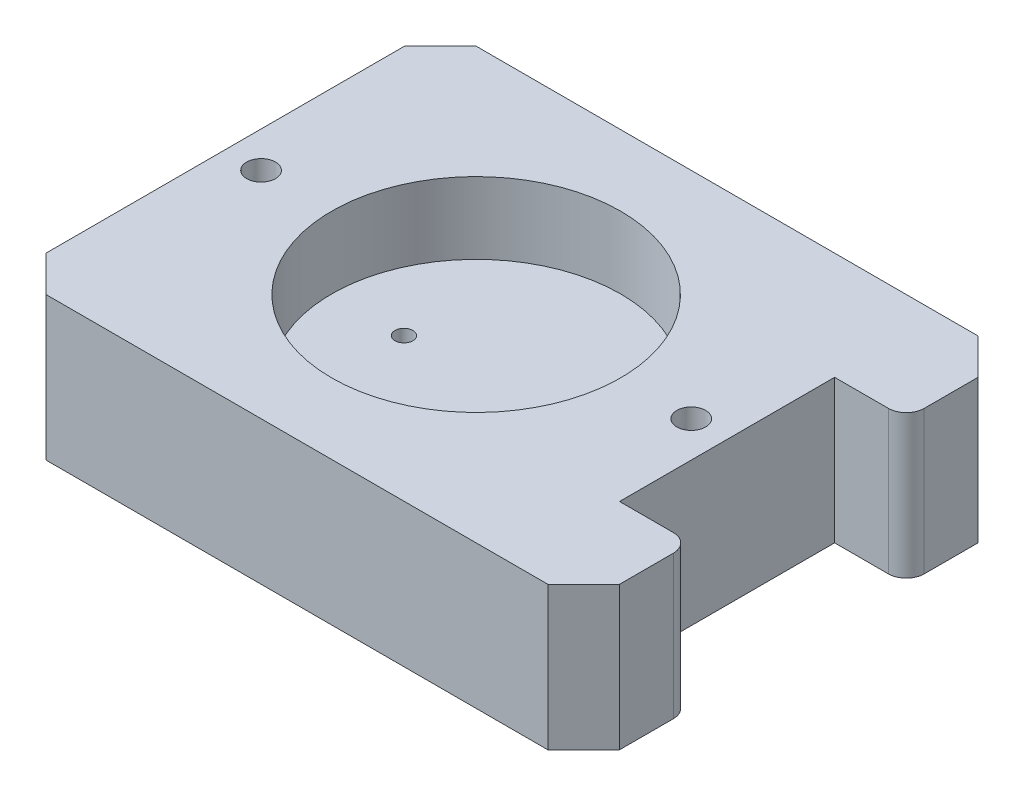
from build123d import *

# Parameters (mm, degrees)
BOX_BODY_DEPTH                 = 25.4
SKETCH3_R                      = 25.5905
SAMPLE_HOLE_DEPTH              = 12.7
CUTOUT_EDGE_FILLET_R           = 3.175
BOX_EDGE_CHAMFER_SIZE          = 6.35
BOX_CLAMP_THREADED_HOLES_D     = 5.1054
BOX_CLAMP_THREADED_HOLES_DEPTH = 12.7
BOX_CLAMP_THREADED_HOLES_TIP   = 1.533816902
SKETCH10_R                     = 1.5875
CUT_EXTRUDE2_DEPTH             = 63.5
CUT_EXTRUDE3_REACH             = 14.7
FLUID_HOLES_R                  = 1.5875


with BuildPart() as part:
    # Sketch1 → box body (new body)
    with BuildSketch(Plane(origin=(0, 0, 0), x_dir=(1, 0, 0), z_dir=(0, 1, 0))):
        Polygon((-50.8, 38.1), (50.8, 38.1), (50.8, 19.05), (38.1, 19.05), (38.1, -19.05), (50.8, -19.05), (50.8, -38.1), (-50.8, -38.1), align=None)
    extrude(amount=BOX_BODY_DEPTH)

    # Sketch3 → sample hole (cut)
    with BuildSketch(Plane(origin=(0, 25.4, 0), x_dir=(1, 0, 0), z_dir=(0, 1, 0))):
        with Locations((-6.35, 0)):
            Circle(SKETCH3_R)
    extrude(amount=-SAMPLE_HOLE_DEPTH, mode=Mode.SUBTRACT)

    # cutout edge fillet
    cutout_edge_fillet_edges = [part.edges().sort_by_distance(p)[0] for p in [
        (50.8, 12.7, -19.05),
        (50.8, 12.7, 19.05),
    ]]
    fillet(cutout_edge_fillet_edges, radius=CUTOUT_EDGE_FILLET_R)

    # box edge chamfer
    box_edge_chamfer_edges = [part.edges().sort_by_distance(p)[0] for p in [
        (50.8, 12.7, 38.1),
        (-50.8, 12.7, 38.1),
        (-50.8, 12.7, -38.1),
        (50.8, 12.7, -38.1),
    ]]
    chamfer(box_edge_chamfer_edges, length=BOX_EDGE_CHAMFER_SIZE)

    # box clamp threaded holes
    with Locations(Plane(origin=(0, 25.4, 0), x_dir=(1, 0, 0), z_dir=(0, 1, 0))):
        with Locations((-44.45, 0), (31.75, 0)):
            Hole(BOX_CLAMP_THREADED_HOLES_D / 2, depth=BOX_CLAMP_THREADED_HOLES_DEPTH)
            with Locations((0, 0, -(BOX_CLAMP_THREADED_HOLES_DEPTH + BOX_CLAMP_THREADED_HOLES_TIP / 2))):  # 118° drill point
                Cone(0, BOX_CLAMP_THREADED_HOLES_D / 2, BOX_CLAMP_THREADED_HOLES_TIP, mode=Mode.SUBTRACT)

    # Sketch10 → Cut-Extrude2 (cut)
    with BuildSketch(Plane.ZY.offset(50.8)):
        with Locations((0, 6.35)):
            Circle(SKETCH10_R)
    extrude(amount=-CUT_EXTRUDE2_DEPTH, mode=Mode.SUBTRACT)

    # fluid holes → Cut-Extrude3 (cut, up to next)
    with BuildSketch(Plane(origin=(0, 12.7, 0), x_dir=(1, 0, 0), z_dir=(0, 1, 0)), mode=Mode.PRIVATE) as cut_extrude3_sk1:
        with Locations((-19.14525, 0)):
            Circle(FLUID_HOLES_R)
    cut_extrude3_tool1 = extrude(cut_extrude3_sk1.sketch, amount=-CUT_EXTRUDE3_REACH, mode=Mode.PRIVATE) & part.part
    add(cut_extrude3_tool1.solids().sort_by_distance((-19.14525, 12.7, 0))[0], mode=Mode.SUBTRACT)
    # fluid holes → Cut-Extrude3 (cut, up to next)
    with BuildSketch(Plane(origin=(0, 12.7, 0), x_dir=(1, 0, 0), z_dir=(0, 1, 0)), mode=Mode.PRIVATE) as cut_extrude3_sk2:
        with Locations((6.44525, 0)):
            Circle(FLUID_HOLES_R)
    cut_extrude3_tool2 = extrude(cut_extrude3_sk2.sketch, amount=-CUT_EXTRUDE3_REACH, mode=Mode.PRIVATE) & part.part
    add(cut_extrude3_tool2.solids().sort_by_distance((6.44525, 12.7, 0))[0], mode=Mode.SUBTRACT)

    # Sketch15 → 1/16 NPT Tapped Hole2 (revolve, cut)
    with BuildSketch(Plane(origin=(-50.8, 6.35, 0), x_dir=(0, 0, 1), z_dir=(0, 1, 0))):
        Polygon((0, 0), (0, 13.530685027), (3.0734, 11.684), (3.0734, 6.858), (3.762574096, 6.858), (3.9679118, 0), align=None)
    revolve(axis=Axis((-57.15, 6.35, 0), (1, 0, 0)), mode=Mode.SUBTRACT)


solid = part.part
